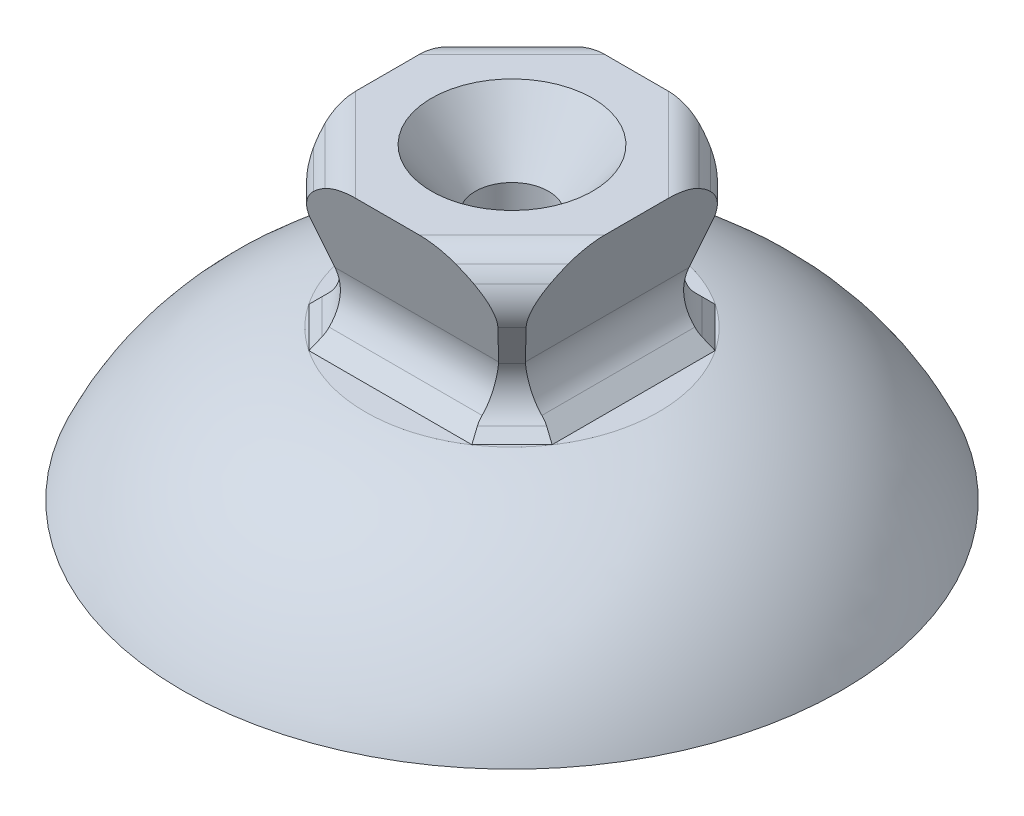
from build123d import *

# Parameters (mm, degrees)
SKETCH4_W           = 17
SKETCH4_H           = 11
BOSS_EXTRUDE2_DEPTH = 8.5
CUT_EXTRUDE1_DEPTH  = 13.5
CUT_EXTRUDE2_DEPTH  = 13.5
CUT_EXTRUDE3_DEPTH  = 13.5
CUT_EXTRUDE4_DEPTH  = 13.5
FILLET1_R           = 2


with BuildPart() as part:
    # Sketch4 → Boss-Extrude2 (new body, symmetric)
    with BuildSketch(Plane.XY):
        Rectangle(SKETCH4_W, SKETCH4_H)
    extrude(amount=BOSS_EXTRUDE2_DEPTH, both=True)

    # Sketch5 → Cut-Extrude1 (cut, symmetric)
    with BuildSketch(Plane(origin=(0, 0, 0), x_dir=(0, 0, -1), z_dir=(1, 0, 0))):
        with BuildLine():
            Line((8.5, 5.5), (6.502509808, -1.291466653))
            ThreePointArc((6.502509808, -1.291466653), (6.473626767, -2.879228009), (7.259285969, -4.259285969))
            Line((7.259285969, -4.259285969), (8.5, -5.5))
            Line((8.5, -5.5), (8.5, 5.5))
        make_face()
        with BuildLine():
            Line((-8.5, -5.5), (-7.259285969, -4.259285969))
            ThreePointArc((-7.259285969, -4.259285969), (-6.473626767, -2.879228009), (-6.502509808, -1.291466653))
            Line((-6.502509808, -1.291466653), (-8.5, 5.5))
            Line((-8.5, 5.5), (-8.5, -5.5))
        make_face()
    extrude(amount=CUT_EXTRUDE1_DEPTH, both=True, mode=Mode.SUBTRACT)

    # Sketch7 → Cut-Extrude2 (cut, symmetric)
    with BuildSketch(Plane.XY):
        with BuildLine():
            Line((8.5, 5.5), (6.502538332, -1.291517059))
            ThreePointArc((6.502538332, -1.291517059), (6.473662442, -2.879270046), (7.259319467, -4.259319467))
            Line((7.259319467, -4.259319467), (8.5, -5.5))
            Line((8.5, -5.5), (8.5, 5.5))
        make_face()
        with BuildLine():
            Line((-8.5, -5.5), (-7.259319467, -4.259319467))
            ThreePointArc((-7.259319467, -4.259319467), (-6.473662442, -2.879270046), (-6.502538332, -1.291517059))
            Line((-6.502538332, -1.291517059), (-8.5, 5.5))
            Line((-8.5, 5.5), (-8.5, -5.5))
        make_face()
    extrude(amount=CUT_EXTRUDE2_DEPTH, both=True, mode=Mode.SUBTRACT)

    # Sketch11 → Cut-Extrude3 (cut, symmetric)
    with BuildSketch(Plane(origin=(0, 0, 0), x_dir=(0.707106781, 0, -0.707106781), z_dir=(0.707106781, 0, 0.707106781))):
        with BuildLine():
            Line((10, -5.5), (9.159523089, -4.659523089))
            ThreePointArc((9.159523089, -4.659523089), (8.341069319, -3.136306549), (8.499291869, -1.414382965))
            Line((8.499291869, -1.414382965), (9.693462893, 1.541294037))
            ThreePointArc((9.693462893, 1.541294037), (9.908907559, 2.799328578), (9.581873492, 4.033069244))
            ThreePointArc((9.581873492, 4.033069244), (9.013209006, 4.854851227), (8.25, 5.5))
            Line((8.25, 5.5), (14, 5.5))
            Line((14, 5.5), (14, -5.5))
            Line((14, -5.5), (10, -5.5))
        make_face()
        with BuildLine():
            Line((-14, 5.5), (-8.25, 5.5))
            ThreePointArc((-8.25, 5.5), (-9.013209006, 4.854851227), (-9.581873492, 4.033069244))
            ThreePointArc((-9.581873492, 4.033069244), (-9.908907559, 2.799328578), (-9.693462893, 1.541294037))
            Line((-9.693462893, 1.541294037), (-8.499291869, -1.414382965))
            ThreePointArc((-8.499291869, -1.414382965), (-8.341069319, -3.136306549), (-9.159523089, -4.659523089))
            Line((-9.159523089, -4.659523089), (-10, -5.5))
            Line((-10, -5.5), (-14, -5.5))
            Line((-14, -5.5), (-14, 5.5))
        make_face()
    extrude(amount=CUT_EXTRUDE3_DEPTH, both=True, mode=Mode.SUBTRACT)

    # Sketch12 → Cut-Extrude4 (cut, symmetric)
    with BuildSketch(Plane(origin=(0, 0, 0), x_dir=(-0.707106781, 0, -0.707106781), z_dir=(0.707106781, 0, -0.707106781))):
        with BuildLine():
            Line((10, -5.5), (9.159523089, -4.659523089))
            ThreePointArc((9.159523089, -4.659523089), (8.341069319, -3.136306549), (8.499291869, -1.414382965))
            Line((8.499291869, -1.414382965), (9.693462893, 1.541294037))
            ThreePointArc((9.693462893, 1.541294037), (9.908907559, 2.799328578), (9.581873492, 4.033069244))
            ThreePointArc((9.581873492, 4.033069244), (9.013209006, 4.854851227), (8.25, 5.5))
            Line((8.25, 5.5), (14, 5.5))
            Line((14, 5.5), (14, -5.5))
            Line((14, -5.5), (10, -5.5))
        make_face()
        with BuildLine():
            Line((-14, 5.5), (-8.25, 5.5))
            ThreePointArc((-8.25, 5.5), (-9.013209006, 4.854851227), (-9.581873492, 4.033069244))
            ThreePointArc((-9.581873492, 4.033069244), (-9.908907559, 2.799328578), (-9.693462893, 1.541294037))
            Line((-9.693462893, 1.541294037), (-8.499291869, -1.414382965))
            ThreePointArc((-8.499291869, -1.414382965), (-8.341069319, -3.136306549), (-9.159523089, -4.659523089))
            Line((-9.159523089, -4.659523089), (-10, -5.5))
            Line((-10, -5.5), (-14, -5.5))
            Line((-14, -5.5), (-14, 5.5))
        make_face()
    extrude(amount=CUT_EXTRUDE4_DEPTH, both=True, mode=Mode.SUBTRACT)

    # Sketch14 → Cut-Revolve1 (revolve, cut)
    with BuildSketch(Plane.XY):
        Polygon((0, 5.5), (5.5, 5.5), (2.5, 1.5), (2.5, -5.5), (0, -5.5), align=None)
    revolve(axis=Axis((0, -5.5, 0), (0, 1, 0)), mode=Mode.SUBTRACT)

    # Fillet1
    fillet1_edges = [part.edges().sort_by_distance(p)[0] for p in [
        (5.833630945, 5.5, -5.833630945),
        (-5.833630945, 5.5, -5.833630945),
        (-5.833630945, 5.5, 5.833630945),
        (5.833630945, 5.5, 5.833630945),
    ]]
    fillet(fillet1_edges, radius=FILLET1_R)

    # Sketch15 → Revolve1 (revolve)
    with BuildSketch(Plane(origin=(0, 0, 0), x_dir=(0, 0, -1), z_dir=(1, 0, 0))):
        with BuildLine():
            Line((0, -15.5), (22.5, -15.5))
            ThreePointArc((22.5, -15.5), (17.455904629, -8.920713416), (9.9979998, -5.3))
            Line((9.9979998, -5.3), (0, -5.3))
            Line((0, -5.3), (0, -5.5))
            Line((0, -5.5), (0, -15.5))
        make_face()
    revolve(axis=Axis((0, -5.5, 0), (0, -1, 0)))


solid = part.part
